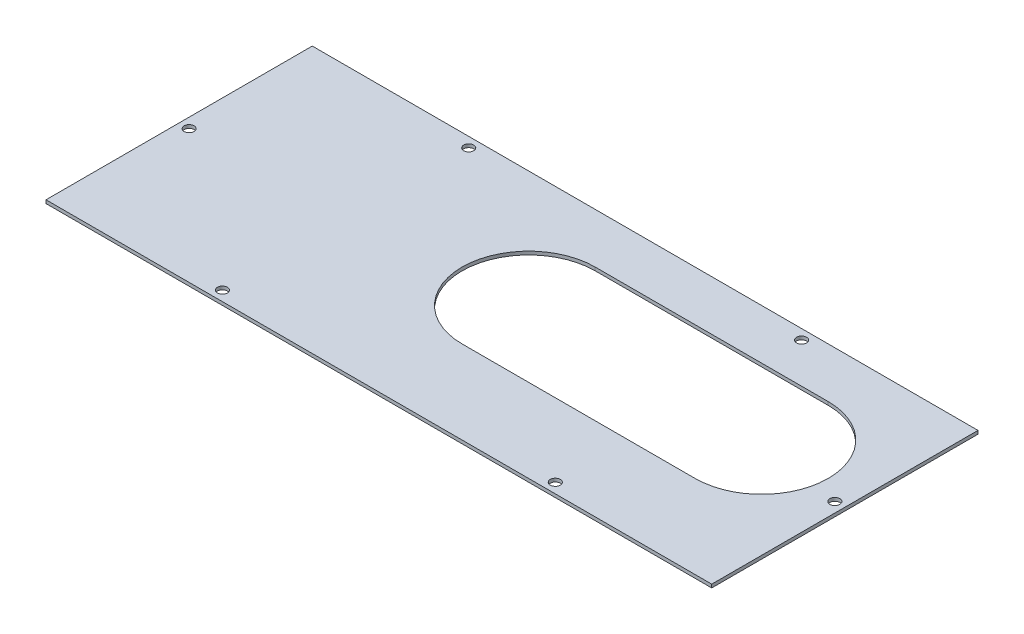
from build123d import *

# Parameters (mm, degrees)
SKETCH_1_W          = 200
SKETCH_1_H          = 80
EXTRUDE_1_DEPTH     = 1
CUT_EXTRUDE_1_REACH = 3
SKETCH_3_R          = 1.5
CUT_EXTRUDE_2_DEPTH = 10


with BuildPart() as part:
    # 草图1 → 凸台-拉伸1 (new body)
    with BuildSketch(Plane(origin=(0, 0, 0), x_dir=(1, 0, 0), z_dir=(0, 1, 0))):
        Rectangle(SKETCH_1_W, SKETCH_1_H)
    extrude(amount=EXTRUDE_1_DEPTH)

    # 草图2 → 切除-拉伸1 (cut, up to next)
    with BuildSketch(Plane(origin=(0, 1, 0), x_dir=(1, 0, 0), z_dir=(0, 1, 0)), mode=Mode.PRIVATE) as cut_extrude_1_sk1:
        with BuildLine():
            Line((0, 25), (70, 25))
            ThreePointArc((70, 25), (90, 5), (70, -15))
            Line((70, -15), (0, -15))
            ThreePointArc((0, -15), (-20, 5), (0, 25))
        make_face()
    cut_extrude_1_tool1 = extrude(cut_extrude_1_sk1.sketch, amount=-CUT_EXTRUDE_1_REACH, mode=Mode.PRIVATE) & part.part
    add(cut_extrude_1_tool1.solids().sort_by_distance((35, 1, -5))[0], mode=Mode.SUBTRACT)

    # 草图3 → 切除-拉伸2 (cut)
    with BuildSketch(Plane(origin=(0, 1, 0), x_dir=(1, 0, 0), z_dir=(0, 1, 0))):
        with Locations((-50, 37)):
            Circle(SKETCH_3_R)
        with Locations((50, 37)):
            Circle(SKETCH_3_R)
        with Locations((50, -37)):
            Circle(SKETCH_3_R)
        with Locations((-50, -37)):
            Circle(SKETCH_3_R)
        with Locations((-97, 0)):
            Circle(SKETCH_3_R)
        with Locations((97, 0)):
            Circle(SKETCH_3_R)
    extrude(amount=-CUT_EXTRUDE_2_DEPTH, mode=Mode.SUBTRACT)


solid = part.part
